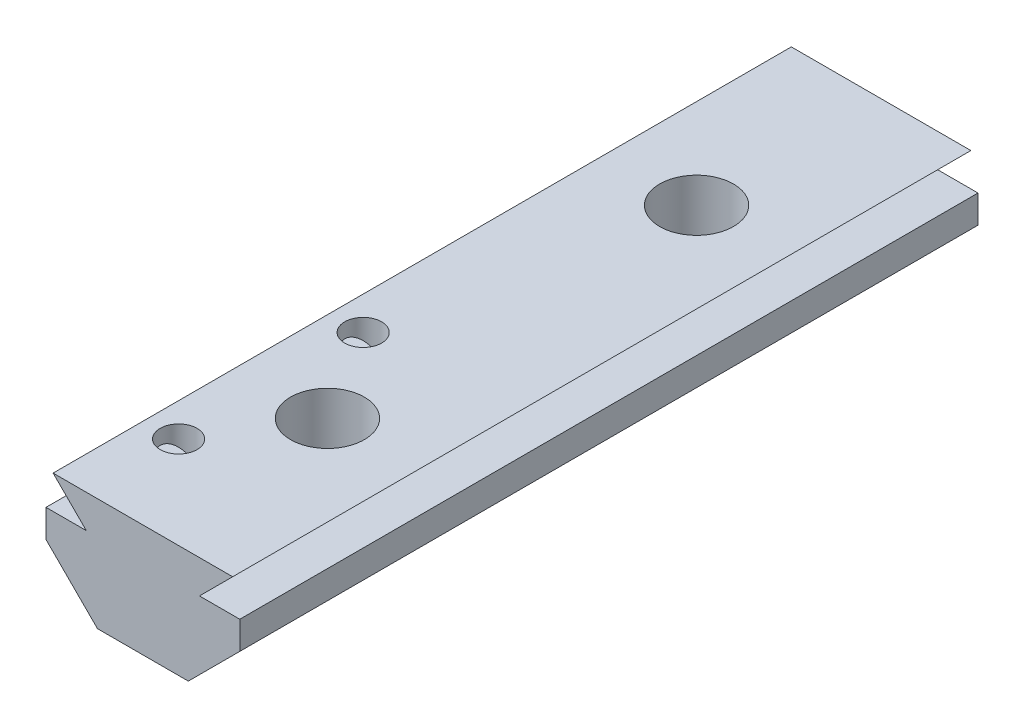
from build123d import *

# Parameters (mm, degrees)
BOSS_EXTRUDE1_DEPTH = 40
SKETCH2_R           = 2
CUT_EXTRUDE1_DEPTH  = 7.1
SKETCH9_R           = 1
CUT_EXTRUDE2_DEPTH  = 4.1


with BuildPart() as part:
    # Sketch1 → Boss-Extrude1 (new body)
    with BuildSketch(Plane.XY):
        Polygon((-2.460653528, 0), (2.460653528, 0), (5.25, 2.789346472), (5.25, 4.3), (3.065, 4.3), (4.865, 6.1), (-4.865, 6.1), (-3.065, 4.3), (-5.25, 4.3), (-5.25, 2.789346472), align=None)
    extrude(amount=BOSS_EXTRUDE1_DEPTH)

    # Sketch2 → Cut-Extrude1 (cut, through all)
    with BuildSketch(Plane(origin=(0, 6.1, 0), x_dir=(1, 0, 0), z_dir=(0, 1, 0))):
        with Locations((0, -30)):
            Circle(SKETCH2_R)
        with Locations((0, -10)):
            Circle(SKETCH2_R)
    extrude(amount=-CUT_EXTRUDE1_DEPTH, mode=Mode.SUBTRACT)

    # Sketch9 → Cut-Extrude2 (cut)
    with BuildSketch(Plane(origin=(0, 6.1, 0), x_dir=(1, 0, 0), z_dir=(0, 1, 0))):
        with Locations((-3.065, -35)):
            Circle(SKETCH9_R)
        with Locations((-3.065, -25)):
            Circle(SKETCH9_R)
    extrude(amount=-CUT_EXTRUDE2_DEPTH, mode=Mode.SUBTRACT)


solid = part.part
